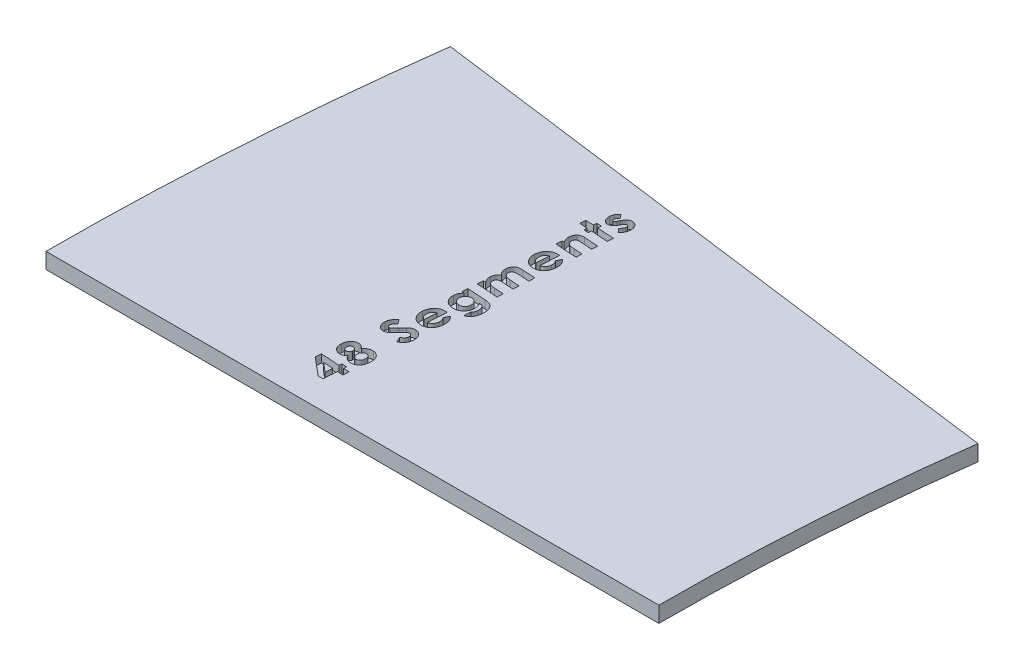
from build123d import *

# Parameters (mm, degrees)
BOSS_EXTRUDE1_DEPTH = 3.175
CUT_EXTRUDE1_DEPTH  = 1.5875


with BuildPart() as part:
    # Sketch1 → Boss-Extrude1 (new body)
    with BuildSketch(Plane(origin=(0, 0, 0), x_dir=(1, 0, 0), z_dir=(0, 1, 0))):
        with BuildLine():
            Line((0, 0), (123.058369544, 0))
            ThreePointArc((123.058369544, 0), (124.044833205, 30.133347612), (127, 60.137659603))
            Line((127, 60.137659603), (4.994411867, 76.2))
            ThreePointArc((4.994411867, 76.2), (1.249941077, 38.181750058), (0, 0))
        make_face()
    extrude(amount=BOSS_EXTRUDE1_DEPTH)

    # Sketch2 → Cut-Extrude1 (cut)
    with BuildSketch(Plane(origin=(0, 3.175, 0), x_dir=(1, 0, 0), z_dir=(0, 1, 0))):
        Polygon((45.403458617, 8.644669615), (45.48041675, 9.838686709), (49.208222072, 9.597318019), (49.244369074, 10.155847499), (50.26348132, 10.090549689), (50.227334318, 9.532020209), (51.415521251, 9.455062076), (51.33972915, 8.286697693), (50.151542217, 8.363655826), (49.975471337, 5.626977975), (48.956359091, 5.692275785), align=None)
        Polygon((49.132429971, 8.428953636), (47.192152193, 8.554885126), (49.040313418, 6.995899916), align=None, mode=Mode.SUBTRACT)
        with BuildLine():
            add(Edge.make_bspline(
                [(48.612358568, 14.746963545), (48.660083235, 14.812453623), (48.753838056, 14.941108488), (48.920903549, 15.108495711), (49.101964982, 15.252658592), (49.300091936, 15.367739108), (49.508431925, 15.456636423), (49.724722624, 15.51677397), (49.947777332, 15.547253835), (50.097811738, 15.543121199), (50.173675843, 15.541031553)],
                knots=[0, 0, 0, 0, 1.058813148, 2.080032062, 3.083098671, 4.079089546, 5.067980208, 6.03892649, 7.008393533, 8, 8, 8, 8], degree=3))
            add(Edge.make_bspline(
                [(50.173675843, 15.541031553), (50.214925689, 15.537212245), (50.29696517, 15.52961624), (50.41839336, 15.510221247), (50.536348025, 15.480685247), (50.651278134, 15.443210922), (50.763403215, 15.397453743), (50.873406157, 15.34421739), (50.979125785, 15.280692541), (51.081849436, 15.210561694), (51.180572226, 15.134919755), (51.27129048, 15.050985709), (51.357274701, 14.964295923), (51.434080169, 14.869780203), (51.505509671, 14.771447769), (51.568399336, 14.666396748), (51.625950063, 14.557455776), (51.674753157, 14.441662665), (51.718505222, 14.320575774), (51.753258491, 14.19136559), (51.780479312, 14.054915264), (51.803800471, 13.911567972), (51.815180276, 13.760270801), (51.822534435, 13.602018332), (51.8228751, 13.435832581), (51.816422809, 13.32282869), (51.813117282, 13.264936468)],
                knots=[0, 0, 0, 0, 0.944636889, 1.878734734, 2.801023885, 3.714840102, 4.633330383, 5.560971107, 6.498930264, 7.44302635, 8.396933534, 9.331872151, 10.259597571, 11.178900164, 12.106286752, 13.02904434, 13.968677379, 14.913771629, 15.89223789, 16.902897162, 17.961587566, 19.064799109, 20.212413555, 21.419099445, 22.677797128, 24, 24, 24, 24], degree=3))
            add(Edge.make_bspline(
                [(51.813117282, 13.264936468), (51.808544104, 13.203481312), (51.799612881, 13.083461981), (51.778540217, 12.90879982), (51.75200781, 12.744179209), (51.719333243, 12.589683891), (51.681195629, 12.445165626), (51.637062859, 12.31071709), (51.586778243, 12.186450666), (51.513134693, 12.035348105), (51.403501941, 11.863722799), (51.246787076, 11.68041689), (51.064293011, 11.522095268), (50.893577005, 11.41129387), (50.747130894, 11.337713495), (50.633753586, 11.289082707), (50.516841757, 11.251200989), (50.397821738, 11.220306768), (50.275680337, 11.199569504), (50.1506561, 11.186916828), (50.022453905, 11.181561808), (49.936184735, 11.18599591), (49.892662054, 11.188232909)],
                knots=[0, 0, 0, 0, 1.154644814, 2.254972708, 3.295486272, 4.278268662, 5.212828494, 6.094946116, 6.928076756, 7.722854426, 9.242249405, 10.729784299, 12.226845655, 13.754110493, 14.529325251, 15.29631934, 16.063278847, 16.829927053, 17.598648219, 18.382065095, 19.183754005, 20, 20, 20, 20], degree=3))
            add(Edge.make_bspline(
                [(49.892662054, 11.188232909), (49.818519314, 11.195685712), (49.672075092, 11.210406236), (49.459711314, 11.26486313), (49.25904995, 11.346297448), (49.070495975, 11.454246251), (48.893883999, 11.588853219), (48.730420284, 11.749879531), (48.578820771, 11.936865322), (48.49088027, 12.075403667), (48.445615947, 12.146711475)],
                knots=[0, 0, 0, 0, 0.986297518, 1.948101384, 2.89298967, 3.847985494, 4.818286911, 5.827091846, 6.881570894, 8, 8, 8, 8], degree=3))
            add(Edge.make_bspline(
                [(48.445615947, 12.146711475), (48.398848976, 12.105123701), (48.307159147, 12.023588041), (48.161318143, 11.916888236), (48.01106566, 11.829581018), (47.859214785, 11.756896262), (47.703199596, 11.704685526), (47.544675123, 11.668971172), (47.382922443, 11.652193594), (47.274552675, 11.655378199), (47.22011598, 11.656977901)],
                knots=[0, 0, 0, 0, 1.105376171, 2.167165192, 3.185955788, 4.172098192, 5.136309341, 6.086007278, 7.038556236, 8, 8, 8, 8], degree=3))
            add(Edge.make_bspline(
                [(47.22011598, 11.656977901), (47.146257343, 11.664443926), (47.000770443, 11.679150518), (46.790728766, 11.740155609), (46.591885052, 11.826118205), (46.407597107, 11.942282016), (46.240175326, 12.083763149), (46.093621018, 12.249069409), (45.970107292, 12.437539554), (45.868732071, 12.64614732), (45.793093249, 12.874400034), (45.745093398, 13.118776704), (45.720291564, 13.377612779), (45.727434075, 13.554470504), (45.73109271, 13.645063004)],
                knots=[0, 0, 0, 0, 0.959435113, 1.889897319, 2.818356756, 3.756692832, 4.699404716, 5.647688167, 6.606595189, 7.608184587, 8.642613508, 9.710508687, 10.827245234, 12, 12, 12, 12], degree=3))
            add(Edge.make_bspline(
                [(45.73109271, 13.645063004), (45.739132865, 13.733980603), (45.754788824, 13.907122814), (45.812227801, 14.156152727), (45.892172609, 14.387351474), (45.997115895, 14.599739846), (46.126342398, 14.790226507), (46.274210202, 14.960468436), (46.446263761, 15.103477511), (46.634489974, 15.223507008), (46.836036438, 15.316702302), (47.045748097, 15.378801759), (47.260627469, 15.412330587), (47.405024617, 15.40874512), (47.477809123, 15.406937837)],
                knots=[0, 0, 0, 0, 1.158948234, 2.256728262, 3.310914617, 4.331802634, 5.324930302, 6.294615419, 7.251644789, 8.221172071, 9.188368295, 10.126338612, 11.055566406, 12, 12, 12, 12], degree=3))
            add(Edge.make_bspline(
                [(47.477809123, 15.406937837), (47.528880635, 15.402220583), (47.62956794, 15.392920534), (47.77645311, 15.35982919), (47.915900955, 15.310381894), (48.051471964, 15.244886098), (48.1857788, 15.156665833), (48.324684661, 15.045017453), (48.469067651, 14.90666803), (48.562933476, 14.802050141), (48.612358568, 14.746963545)],
                knots=[0, 0, 0, 0, 0.909223446, 1.792530799, 2.662713627, 3.529309977, 4.456964102, 5.506950576, 6.68728371, 8, 8, 8, 8], degree=3))
        make_face()
        with BuildLine():
            add(Edge.make_bspline(
                [(46.792182119, 13.53778803), (46.791126306, 13.490625317), (46.789083232, 13.399362066), (46.816341137, 13.267447245), (46.863460381, 13.14585695), (46.937324562, 13.040029297), (47.026774651, 12.949621279), (47.134495058, 12.883037393), (47.254766879, 12.836739632), (47.341349192, 12.82766025), (47.385692569, 12.823010219)],
                knots=[0, 0, 0, 0, 1.085231635, 2.100001469, 3.085829323, 4.073287319, 5.056174103, 5.999140924, 6.975254336, 8, 8, 8, 8], degree=3))
            add(Edge.make_bspline(
                [(47.385692569, 12.823010219), (47.430921453, 12.822250627), (47.518979371, 12.820771748), (47.647514999, 12.851134433), (47.764739634, 12.908941767), (47.870816583, 12.98934007), (47.96010948, 13.090035327), (48.027481157, 13.206764068), (48.073632869, 13.336052736), (48.083667526, 13.427802592), (48.088810057, 13.474822285)],
                knots=[0, 0, 0, 0, 1.012915849, 1.972086262, 2.93248722, 3.92936585, 4.943522166, 5.93315123, 6.940787512, 8, 8, 8, 8], degree=3))
            add(Edge.make_bspline(
                [(48.088810057, 13.474822285), (48.089955132, 13.523539503), (48.092165422, 13.617576264), (48.063896902, 13.753295697), (48.013831077, 13.877235891), (47.938248679, 13.985502176), (47.844947681, 14.077285699), (47.734226399, 14.148025459), (47.606448456, 14.193132873), (47.515476406, 14.203105053), (47.468480864, 14.208256613)],
                knots=[0, 0, 0, 0, 1.082971396, 2.090413337, 3.065299682, 4.043260173, 5.011155227, 5.965228633, 6.948850968, 8, 8, 8, 8], degree=3))
            add(Edge.make_bspline(
                [(47.468480864, 14.208256613), (47.423599796, 14.209108914), (47.336609181, 14.210760884), (47.21113756, 14.179594061), (47.096014618, 14.12603118), (46.997666556, 14.043249393), (46.912134614, 13.943577144), (46.850783753, 13.822511409), (46.807322003, 13.686244636), (46.797370232, 13.588660916), (46.792182119, 13.53778803)],
                knots=[0, 0, 0, 0, 1.003752875, 1.94552146, 2.874347794, 3.829600713, 4.808237546, 5.803459357, 6.854887263, 8, 8, 8, 8], degree=3))
        make_face(mode=Mode.SUBTRACT)
        with BuildLine():
            add(Edge.make_bspline(
                [(49.117250562, 13.434011154), (49.115490541, 13.398647877), (49.112046999, 13.329458414), (49.117031259, 13.227257161), (49.129597575, 13.128907995), (49.150977543, 13.034276291), (49.178729605, 12.942786983), (49.214739731, 12.855144706), (49.259780679, 12.772129335), (49.310286326, 12.693333132), (49.367292377, 12.621041585), (49.428920292, 12.557366906), (49.49334468, 12.501136498), (49.562661665, 12.456272758), (49.634022877, 12.418017942), (49.709659376, 12.389763334), (49.78891109, 12.371219323), (49.843215953, 12.365368065), (49.87050744, 12.362427453)],
                knots=[0, 0, 0, 0, 1.168923599, 2.287039063, 3.37466695, 4.439939738, 5.487661528, 6.529546381, 7.563411425, 8.603237685, 9.617791486, 10.598391904, 11.527199418, 12.435188665, 13.319544345, 14.197070922, 15.093918773, 16, 16, 16, 16], degree=3))
            add(Edge.make_bspline(
                [(49.87050744, 12.362427453), (49.8992874, 12.36132414), (49.955811911, 12.359157205), (50.039409831, 12.368216346), (50.120526, 12.384033079), (50.198561953, 12.410117123), (50.273978503, 12.443836231), (50.345716521, 12.487743219), (50.414333488, 12.540676432), (50.480895647, 12.600930216), (50.54178994, 12.668934926), (50.596526943, 12.743309482), (50.642474892, 12.824444287), (50.684387833, 12.910201372), (50.714794122, 13.003602412), (50.74096821, 13.101924491), (50.759799689, 13.206427946), (50.765470741, 13.278469816), (50.768352325, 13.315075858)],
                knots=[0, 0, 0, 0, 0.944012823, 1.854063158, 2.752145138, 3.651675346, 4.54794375, 5.457994086, 6.404502821, 7.38868266, 8.400336293, 9.395367758, 10.412715021, 11.456897332, 12.521831869, 13.629455457, 14.795474756, 16, 16, 16, 16], degree=3))
            add(Edge.make_bspline(
                [(50.768352325, 13.315075858), (50.769992071, 13.351990521), (50.773202591, 13.424267128), (50.769912248, 13.530719369), (50.758184493, 13.632054917), (50.739591448, 13.727981914), (50.714385886, 13.818480606), (50.679863658, 13.902862867), (50.639210739, 13.982915602), (50.590343967, 14.056908615), (50.536111827, 14.124142526), (50.476796233, 14.183700351), (50.412657241, 14.234897335), (50.34378825, 14.278784229), (50.269451515, 14.311829661), (50.191911071, 14.339960193), (50.108560905, 14.356713331), (50.051297613, 14.36264543), (50.022091641, 14.365670976)],
                knots=[0, 0, 0, 0, 1.225686815, 2.399818307, 3.529117038, 4.606492754, 5.639183039, 6.640145975, 7.626380683, 8.613542342, 9.576226871, 10.48807912, 11.396368183, 12.294438496, 13.188797759, 14.090102707, 15.025895937, 16, 16, 16, 16], degree=3))
            add(Edge.make_bspline(
                [(50.022091641, 14.365670976), (49.992925489, 14.366753833), (49.935243268, 14.368895411), (49.850069363, 14.360002201), (49.767457911, 14.343988448), (49.687957767, 14.318218938), (49.611617312, 14.283009269), (49.538751751, 14.237979594), (49.468970892, 14.184293736), (49.402777648, 14.122464987), (49.341372565, 14.054587927), (49.287149457, 13.980276134), (49.240986644, 13.901042743), (49.200661197, 13.817414651), (49.167972937, 13.72885302), (49.143729662, 13.634630569), (49.12611861, 13.535980915), (49.120230673, 13.468278132), (49.117250562, 13.434011154)],
                knots=[0, 0, 0, 0, 0.965997967, 1.910464878, 2.829836423, 3.750289794, 4.672273579, 5.608804393, 6.582498314, 7.58489814, 8.606311822, 9.610942972, 10.626983754, 11.640818325, 12.683923904, 13.749136132, 14.860751353, 16, 16, 16, 16], degree=3))
        make_face(mode=Mode.SUBTRACT)
        with BuildLine():
            Line((47.31786749, 23.569500264), (47.981339879, 22.641338539))
            add(Edge.make_bspline(
                [(47.981339879, 22.641338539), (47.931383169, 22.606364631), (47.835539776, 22.539266179), (47.70639689, 22.429675712), (47.594625686, 22.319346271), (47.50212321, 22.205915871), (47.427149176, 22.091540452), (47.373187914, 21.974282928), (47.334973998, 21.855653687), (47.325879119, 21.77445969), (47.321365587, 21.734165395)],
                knots=[0, 0, 0, 0, 1.259962512, 2.417274506, 3.496694533, 4.501793993, 5.437824047, 6.314896232, 7.163730449, 8, 8, 8, 8], degree=3))
            add(Edge.make_bspline(
                [(47.321365587, 21.734165395), (47.320211985, 21.696810578), (47.317989438, 21.624842226), (47.333444486, 21.520818999), (47.363712603, 21.42596724), (47.408707656, 21.342711011), (47.464020548, 21.274051882), (47.5259145, 21.22200974), (47.593413595, 21.187147372), (47.641666905, 21.180207424), (47.665345121, 21.176801947)],
                knots=[0, 0, 0, 0, 1.240335475, 2.389648993, 3.47647956, 4.534434871, 5.517131834, 6.388931619, 7.209438151, 8, 8, 8, 8], degree=3))
            add(Edge.make_bspline(
                [(47.665345121, 21.176801947), (47.689528087, 21.176659324), (47.738025637, 21.176373302), (47.810158094, 21.19280456), (47.881590461, 21.220630367), (47.925059894, 21.249390899), (47.947524942, 21.264254371)],
                knots=[0, 0, 0, 0, 0.961218949, 1.9276694, 2.929017405, 4, 4, 4, 4], degree=3))
            add(Edge.make_bspline(
                [(47.947524942, 21.264254371), (47.965161134, 21.278070251), (48.006204463, 21.31022287), (48.072409902, 21.370170963), (48.150819825, 21.44886094), (48.244525398, 21.543293502), (48.351596778, 21.655089344), (48.471542292, 21.785039652), (48.605703969, 21.931555558), (48.698590459, 22.036040859), (48.747423113, 22.090971284)],
                knots=[0, 0, 0, 0, 0.466860746, 1.086488491, 1.859851877, 2.782151811, 3.859346126, 5.08609297, 6.468089265, 8, 8, 8, 8], degree=3))
            add(Edge.make_bspline(
                [(48.747423113, 22.090971284), (48.792976655, 22.142207089), (48.87951575, 22.239540908), (49.001056568, 22.378663621), (49.11144539, 22.500013091), (49.207683393, 22.605878147), (49.291004283, 22.69591274), (49.359936574, 22.770769224), (49.417564576, 22.827850128), (49.451297599, 22.860574288), (49.465699021, 22.874545002)],
                knots=[0, 0, 0, 0, 1.547564171, 2.939942712, 4.169874708, 5.250488515, 6.169415565, 6.939095653, 7.547074963, 8, 8, 8, 8], degree=3))
            add(Edge.make_bspline(
                [(49.465699021, 22.874545002), (49.524357116, 22.927974281), (49.636774275, 23.030370509), (49.810539432, 23.161896192), (49.977723524, 23.269213384), (50.142773084, 23.348783191), (50.308213792, 23.406518187), (50.477914458, 23.44176435), (50.653108547, 23.460754716), (50.77123259, 23.456314371), (50.831122865, 23.454063065)],
                knots=[0, 0, 0, 0, 1.242832467, 2.381865548, 3.411028091, 4.350899025, 5.246607285, 6.149760917, 7.061907069, 8, 8, 8, 8], degree=3))
            add(Edge.make_bspline(
                [(50.831122865, 23.454063065), (50.889227245, 23.44875077), (51.003266649, 23.438324516), (51.168679003, 23.400762177), (51.326406726, 23.350182272), (51.474405532, 23.280928664), (51.613655693, 23.196101841), (51.743644957, 23.094955116), (51.865492068, 22.977952007), (51.976141522, 22.845100138), (52.077302822, 22.701452115), (52.160419056, 22.545192732), (52.231217423, 22.381306011), (52.286378738, 22.20796581), (52.323945609, 22.024952213), (52.349038746, 21.833246187), (52.356667324, 21.631921706), (52.351018759, 21.495111495), (52.348130912, 21.425166831)],
                knots=[0, 0, 0, 0, 0.985764863, 1.934725727, 2.861807049, 3.782293506, 4.690921729, 5.613916041, 6.562284815, 7.541938189, 8.533864006, 9.527987119, 10.529191171, 11.549905542, 12.598020906, 13.684831924, 14.81636282, 16, 16, 16, 16], degree=3))
            add(Edge.make_bspline(
                [(52.348130912, 21.425166831), (52.343779082, 21.370287272), (52.335197934, 21.262073117), (52.310446031, 21.103546148), (52.276562866, 20.950852606), (52.233362323, 20.804518677), (52.182489518, 20.66330934), (52.119926739, 20.529466485), (52.050194965, 20.400460006), (51.97047784, 20.277801087), (51.881396405, 20.159996259), (51.780927956, 20.048728442), (51.671067656, 19.94191003), (51.549668106, 19.841351853), (51.418545384, 19.745059776), (51.27670761, 19.653433079), (51.123886041, 19.568807049), (51.017159917, 19.51704349), (50.962884517, 19.490719214)],
                knots=[0, 0, 0, 0, 1.050146701, 2.070729804, 3.058558941, 4.032481406, 4.980388222, 5.919492294, 6.848763778, 7.776524707, 8.708042668, 9.663923483, 10.634224774, 11.629376606, 12.669206861, 13.73688427, 14.849096104, 16, 16, 16, 16], degree=3))
            Line((50.962884517, 19.490719214), (50.468486814, 20.528487978))
            add(Edge.make_bspline(
                [(50.468486814, 20.528487978), (50.531654807, 20.562049824), (50.652535394, 20.626275004), (50.817473032, 20.735204708), (50.95839394, 20.850719967), (51.076060659, 20.971939781), (51.170537588, 21.099371696), (51.239443418, 21.233335809), (51.287884469, 21.373145246), (51.298191394, 21.469882684), (51.303365954, 21.518449416)],
                knots=[0, 0, 0, 0, 1.264744856, 2.420262152, 3.489788695, 4.481701623, 5.401647069, 6.284145582, 7.138560588, 8, 8, 8, 8], degree=3))
            add(Edge.make_bspline(
                [(51.303365954, 21.518449416), (51.304558201, 21.567887979), (51.306872437, 21.663851799), (51.284113531, 21.802989691), (51.240991755, 21.931730635), (51.175721697, 22.045228556), (51.098125917, 22.14265399), (51.008179592, 22.215248299), (50.909367427, 22.264695969), (50.838649904, 22.274020195), (50.80313809, 22.278702488)],
                knots=[0, 0, 0, 0, 1.179276943, 2.289061677, 3.349098182, 4.4052234, 5.401529699, 6.306411478, 7.149540335, 8, 8, 8, 8], degree=3))
            add(Edge.make_bspline(
                [(50.80313809, 22.278702488), (50.76996628, 22.278900624), (50.702358223, 22.27930445), (50.600112523, 22.25356888), (50.49708846, 22.210049805), (50.411551927, 22.156940176), (50.339769458, 22.101427103), (50.277402538, 22.047810182), (50.207180411, 21.983490028), (50.130347285, 21.907482653), (50.046488406, 21.819531402), (49.954369825, 21.720753595), (49.855691314, 21.609952708), (49.787838099, 21.53211791), (49.752542971, 21.491630673)],
                knots=[0, 0, 0, 0, 0.878417966, 1.790319345, 2.776241537, 3.842568915, 4.454011902, 5.186637811, 6.027267838, 6.983979148, 8.057732953, 9.256214254, 10.572768142, 12, 12, 12, 12], degree=3))
            add(Edge.make_bspline(
                [(49.752542971, 21.491630673), (49.685352759, 21.413504912), (49.556444071, 21.263615679), (49.36425605, 21.054450969), (49.18766918, 20.864542479), (49.022275668, 20.697418288), (48.868105853, 20.552977836), (48.728135217, 20.428566993), (48.599256533, 20.327875069), (48.481874758, 20.245780561), (48.369397316, 20.182055393), (48.260922111, 20.127975981), (48.153100441, 20.08325016), (48.045549952, 20.047915962), (47.938148956, 20.022723802), (47.831949669, 20.004375232), (47.72603968, 19.997224765), (47.656014158, 20.000036759), (47.621035893, 20.00144137)],
                knots=[0, 0, 0, 0, 1.836570026, 3.523576208, 5.06257668, 6.458740922, 7.713443808, 8.827894704, 9.795229329, 10.627303203, 11.378337667, 12.097142506, 12.786742063, 13.457143101, 14.112483532, 14.751433223, 15.37633167, 16, 16, 16, 16], degree=3))
            add(Edge.make_bspline(
                [(47.621035893, 20.00144137), (47.571881903, 20.006112347), (47.474616852, 20.015355193), (47.332978441, 20.049385806), (47.196617904, 20.095195516), (47.067698643, 20.159012585), (46.945463124, 20.238355403), (46.828602967, 20.331618693), (46.718588551, 20.440856687), (46.617320652, 20.564150043), (46.523813317, 20.69647796), (46.446329194, 20.838795698), (46.379612191, 20.985936064), (46.330408785, 21.140826396), (46.292466848, 21.300946899), (46.269485297, 21.467612852), (46.259667407, 21.640829419), (46.264704963, 21.758267165), (46.267272371, 21.818119722)],
                knots=[0, 0, 0, 0, 0.940109522, 1.860272196, 2.769362089, 3.677243568, 4.593820015, 5.54261843, 6.522299789, 7.543004526, 8.580907746, 9.605637889, 10.62720271, 11.655755738, 12.69809198, 13.760535432, 14.858649072, 16, 16, 16, 16], degree=3))
            add(Edge.make_bspline(
                [(46.267272371, 21.818119722), (46.274817966, 21.895351776), (46.289824173, 22.048946056), (46.343973231, 22.274097086), (46.420787819, 22.492074759), (46.506417624, 22.66696984), (46.587675242, 22.805329403), (46.662401834, 22.909522757), (46.744237147, 23.017620919), (46.840024058, 23.124120355), (46.943824948, 23.234146981), (47.0576829, 23.346387851), (47.18435577, 23.457599138), (47.272633181, 23.531587711), (47.31786749, 23.569500264)],
                knots=[0, 0, 0, 0, 1.323588687, 2.632270434, 3.942011782, 5.26276926, 5.950186656, 6.679234955, 7.450436607, 8.263881052, 9.122931744, 10.033328008, 10.992255797, 12, 12, 12, 12], degree=3))
        make_face()
        with BuildLine():
            Line((50.902312635, 29.667928965), (50.660943945, 25.92846332))
            add(Edge.make_bspline(
                [(50.660943945, 25.92846332), (50.698392047, 25.933564462), (50.77238895, 25.943644244), (50.879870172, 25.971279678), (50.982574698, 26.005944337), (51.080140561, 26.049032082), (51.171742276, 26.102150501), (51.257967622, 26.163944182), (51.339074006, 26.234676775), (51.414866327, 26.313553721), (51.482920193, 26.401324411), (51.545860167, 26.494340988), (51.597399568, 26.59566263), (51.644055607, 26.701782088), (51.679313001, 26.815911152), (51.708800469, 26.936113095), (51.729833579, 27.063214817), (51.737027908, 27.150397716), (51.740689872, 27.194774418)],
                knots=[0, 0, 0, 0, 0.994835371, 1.965780117, 2.917698247, 3.848119578, 4.770108853, 5.702049976, 6.638255784, 7.601395555, 8.578421378, 9.560957341, 10.554738414, 11.568415358, 12.611048672, 13.696247782, 14.82737411, 16, 16, 16, 16], degree=3))
            add(Edge.make_bspline(
                [(51.740689872, 27.194774418), (51.74274016, 27.248406898), (51.746784382, 27.354197696), (51.737497566, 27.510796652), (51.713603536, 27.662445957), (51.678086269, 27.809517915), (51.627407237, 27.95164007), (51.562953795, 28.088047803), (51.485654955, 28.220293268), (51.424338717, 28.30266648), (51.393212241, 28.344482284)],
                knots=[0, 0, 0, 0, 1.047388229, 2.065987588, 3.056531067, 4.041127734, 5.015525619, 5.996519287, 6.982956295, 8, 8, 8, 8], degree=3))
            Line((51.393212241, 28.344482284), (51.881779782, 29.297130688))
            add(Edge.make_bspline(
                [(51.881779782, 29.297130688), (51.91869169, 29.263715251), (51.992085495, 29.197273655), (52.094426663, 29.091594324), (52.187674813, 28.981023497), (52.274993922, 28.868510495), (52.351163668, 28.7497575), (52.422341546, 28.628900428), (52.48206814, 28.502185859), (52.53658665, 28.372633288), (52.581777123, 28.237609948), (52.620602271, 28.097624326), (52.650673843, 27.951904888), (52.672702978, 27.800408167), (52.687599892, 27.643569519), (52.695924372, 27.48134262), (52.696074203, 27.313588322), (52.689631434, 27.20019557), (52.686342082, 27.142302964)],
                knots=[0, 0, 0, 0, 0.998802116, 1.985968494, 2.948526296, 3.899932011, 4.840796933, 5.77709413, 6.711831264, 7.648810172, 8.59576323, 9.56627996, 10.561911074, 11.578724665, 12.636344111, 13.721659964, 14.836794776, 16, 16, 16, 16], degree=3))
            add(Edge.make_bspline(
                [(52.686342082, 27.142302964), (52.678965936, 27.053489578), (52.664518939, 26.879538737), (52.616789387, 26.626900405), (52.551924686, 26.38799047), (52.467717959, 26.162510252), (52.364096765, 25.950999685), (52.240314402, 25.753856122), (52.099453458, 25.569487885), (51.938278558, 25.403222013), (51.765851042, 25.252581359), (51.58194254, 25.123988623), (51.390141606, 25.016518099), (51.188424102, 24.934043671), (50.97916654, 24.869658307), (50.759934341, 24.83105541), (50.532545011, 24.812485559), (50.378778684, 24.818726977), (50.300639958, 24.82189865)],
                knots=[0, 0, 0, 0, 1.146840864, 2.246214718, 3.304922167, 4.331146756, 5.340564401, 6.332044593, 7.324042507, 8.322207038, 9.308533163, 10.267917242, 11.206557428, 12.133179881, 13.068880295, 14.020084305, 14.993875368, 16, 16, 16, 16], degree=3))
            add(Edge.make_bspline(
                [(50.300639958, 24.82189865), (50.220757174, 24.829336226), (50.063789788, 24.843950851), (49.835235957, 24.891275579), (49.618532952, 24.958537109), (49.413830278, 25.048103973), (49.220992907, 25.158237314), (49.038977469, 25.287940998), (48.870300906, 25.440237372), (48.714182864, 25.610457781), (48.573513121, 25.795401539), (48.454418564, 25.992944579), (48.353738576, 26.198763771), (48.277753003, 26.415583746), (48.219678197, 26.640930785), (48.183780193, 26.87602365), (48.169761742, 27.120833085), (48.176299275, 27.286508898), (48.179627171, 27.370845298)],
                knots=[0, 0, 0, 0, 1.038080059, 2.039797629, 3.015440869, 3.970929085, 4.926536557, 5.885912811, 6.858800873, 7.863156722, 8.872630486, 9.861665724, 10.845219295, 11.833652654, 12.830809453, 13.854247172, 14.907715822, 16, 16, 16, 16], degree=3))
            add(Edge.make_bspline(
                [(48.179627171, 27.370845298), (48.187498774, 27.460032712), (48.202880228, 27.634308779), (48.25011252, 27.887960849), (48.316531209, 28.127478172), (48.401232486, 28.353632765), (48.506782098, 28.565068066), (48.632714164, 28.761695027), (48.775949421, 28.946027929), (48.939659196, 29.112873555), (49.116698366, 29.264122009), (49.309580268, 29.390814418), (49.511900252, 29.498564696), (49.727059341, 29.581227876), (49.953343796, 29.64212404), (50.191277284, 29.680083932), (50.440789146, 29.697099741), (50.610413991, 29.690141228), (50.697090947, 29.686585482)],
                knots=[0, 0, 0, 0, 1.116171507, 2.181047453, 3.212496527, 4.21276363, 5.18831663, 6.153857981, 7.120676207, 8.094252009, 9.064370131, 10.01894602, 10.966517271, 11.918048095, 12.886990705, 13.883963422, 14.918722022, 16, 16, 16, 16], degree=3))
            Line((50.697090947, 29.686585482), (50.902312635, 29.667928965))
        make_face()
        with BuildLine():
            add(Edge.make_bspline(
                [(49.979981071, 28.554368101), (49.920807671, 28.536297754), (49.802732665, 28.500240059), (49.64045465, 28.407344762), (49.49202244, 28.288002019), (49.363067546, 28.139540776), (49.253485719, 27.970746321), (49.171338108, 27.782775026), (49.113857556, 27.580291427), (49.099795983, 27.438457174), (49.092630477, 27.366181169)],
                knots=[0, 0, 0, 0, 0.934306292, 1.864321171, 2.810085895, 3.806617566, 4.828527451, 5.845545187, 6.902131309, 8, 8, 8, 8], degree=3))
            add(Edge.make_bspline(
                [(49.092630477, 27.366181169), (49.09089294, 27.326155912), (49.087467842, 27.247256593), (49.092260728, 27.130291027), (49.105640711, 27.016689448), (49.124235769, 26.905948138), (49.154719828, 26.79925384), (49.190267704, 26.694699778), (49.235598021, 26.593820889), (49.27171815, 26.529493548), (49.289689938, 26.497487092)],
                knots=[0, 0, 0, 0, 1.062818384, 2.095068298, 3.101963213, 4.097381956, 5.07075439, 6.042814411, 7.026190488, 8, 8, 8, 8], degree=3))
            add(Edge.make_bspline(
                [(49.289689938, 26.497487092), (49.317181098, 26.456803614), (49.375524221, 26.37046309), (49.496509977, 26.254613969), (49.644387411, 26.139056641), (49.757981041, 26.070654782), (49.817902579, 26.034572261)],
                knots=[0, 0, 0, 0, 0.828720824, 1.758753057, 2.81772453, 4, 4, 4, 4], degree=3))
            Line((49.817902579, 26.034572261), (49.979981071, 28.554368101))
        make_face(mode=Mode.SUBTRACT)
        with BuildLine():
            Line((48.771568378, 34.721687852), (48.847360478, 35.881890009))
            Line((48.847360478, 35.881890009), (52.51453212, 35.644019416))
            add(Edge.make_bspline(
                [(52.51453212, 35.644019416), (52.602087328, 35.636868115), (52.771563323, 35.62302572), (53.015769491, 35.58645676), (53.240530515, 35.533734962), (53.446540627, 35.468706635), (53.634920037, 35.391334801), (53.80298526, 35.297520399), (53.954014891, 35.191877639), (54.039570567, 35.108078078), (54.081679556, 35.066833418)],
                knots=[0, 0, 0, 0, 1.23386892, 2.388334938, 3.465088934, 4.473544334, 5.420668639, 6.320116555, 7.173191121, 8, 8, 8, 8], degree=3))
            add(Edge.make_bspline(
                [(54.081679556, 35.066833418), (54.133885584, 35.008285271), (54.238543849, 34.890912859), (54.36624236, 34.689528888), (54.473000478, 34.471867206), (54.556294527, 34.234727587), (54.614995327, 33.978879428), (54.650159261, 33.704397685), (54.664928589, 33.411869963), (54.655541018, 33.211272758), (54.650703327, 33.107899123)],
                knots=[0, 0, 0, 0, 0.894926534, 1.794073614, 2.713572071, 3.660174313, 4.658680894, 5.706853178, 6.818274054, 8, 8, 8, 8], degree=3))
            add(Edge.make_bspline(
                [(54.650703327, 33.107899123), (54.642235285, 32.998883896), (54.625955136, 32.789297765), (54.576298734, 32.490063442), (54.511554472, 32.218346428), (54.425634806, 31.973996562), (54.322048707, 31.754150302), (54.203349539, 31.553668469), (54.064342912, 31.374701972), (53.910425133, 31.213780194), (53.739343782, 31.074203839), (53.55193345, 30.956970447), (53.349872856, 30.859998631), (53.206247368, 30.814926847), (53.133695281, 30.792158939)],
                knots=[0, 0, 0, 0, 1.323068853, 2.543652737, 3.66767639, 4.700400896, 5.67279012, 6.605568507, 7.514657804, 8.409759522, 9.29596319, 10.17971546, 11.080487429, 12, 12, 12, 12], degree=3))
            Line((53.133695281, 30.792158939), (53.216483575, 32.075960522))
            add(Edge.make_bspline(
                [(53.216483575, 32.075960522), (53.247588085, 32.103952835), (53.310140958, 32.16024691), (53.391014765, 32.260407083), (53.46245453, 32.372350774), (53.521747732, 32.498424889), (53.570247566, 32.636948089), (53.610374347, 32.788019317), (53.637793162, 32.95243132), (53.647554626, 33.066611557), (53.652579662, 33.125389608)],
                knots=[0, 0, 0, 0, 0.858486583, 1.726463573, 2.634642424, 3.581081705, 4.581170094, 5.646362337, 6.788387222, 8, 8, 8, 8], degree=3))
            add(Edge.make_bspline(
                [(53.652579662, 33.125389608), (53.655766822, 33.199999474), (53.661829564, 33.341925332), (53.651207002, 33.544837881), (53.620352141, 33.725788125), (53.570973603, 33.884930525), (53.508282073, 34.023303114), (53.433725747, 34.141929052), (53.346241477, 34.238945022), (53.26336069, 34.304947558), (53.188196795, 34.347258472), (53.121860715, 34.374907675), (53.04600037, 34.400641124), (52.959763188, 34.422356468), (52.8638768, 34.440523604), (52.758566266, 34.457144421), (52.643383158, 34.469758356), (52.563140625, 34.475177058), (52.521528314, 34.477987098)],
                knots=[0, 0, 0, 0, 1.73616652, 3.302605099, 4.715916807, 5.993939219, 7.166982346, 8.240207595, 9.238649617, 10.19161721, 10.689445005, 11.240185385, 11.86049324, 12.551111064, 13.306326133, 14.129662517, 15.030077156, 16, 16, 16, 16], degree=3))
            add(Edge.make_bspline(
                [(52.521528314, 34.477987098), (52.562843416, 34.424222809), (52.64373363, 34.318958522), (52.74757166, 34.153191246), (52.827747769, 33.982694886), (52.891042237, 33.809645594), (52.934181162, 33.629603561), (52.960641677, 33.441060428), (52.971514215, 33.242421435), (52.965409516, 33.107112795), (52.96228853, 33.037937184)],
                knots=[0, 0, 0, 0, 1.052449834, 2.060575592, 3.029617018, 3.972603352, 4.916651097, 5.898089827, 6.925412889, 8, 8, 8, 8], degree=3))
            add(Edge.make_bspline(
                [(52.96228853, 33.037937184), (52.955559157, 32.96156481), (52.94232219, 32.811337049), (52.89814624, 32.592442532), (52.837050286, 32.383459582), (52.754020851, 32.185796612), (52.655677739, 31.996831662), (52.535104928, 31.819581942), (52.395876367, 31.653053207), (52.240803187, 31.497371911), (52.071214444, 31.358012963), (51.891304509, 31.237530612), (51.702396721, 31.136600368), (51.502743717, 31.060917138), (51.295976668, 31.001119675), (51.079227237, 30.965664355), (50.853883238, 30.950097677), (50.700968199, 30.955934286), (50.623227699, 30.958901561)],
                knots=[0, 0, 0, 0, 1.05170353, 2.068746279, 3.059633396, 4.035584716, 5.006931398, 5.979142195, 6.97170843, 7.982772074, 8.991072858, 9.979543945, 10.950890627, 11.923847754, 12.905151095, 13.900681141, 14.93272697, 16, 16, 16, 16], degree=3))
            add(Edge.make_bspline(
                [(50.623227699, 30.958901561), (50.540232046, 30.966277428), (50.378222194, 30.980675328), (50.14311479, 31.028205194), (49.921946083, 31.095040613), (49.715218057, 31.184895243), (49.521398797, 31.293250698), (49.34214143, 31.423889001), (49.176219879, 31.574546351), (49.079336136, 31.689240051), (49.030427552, 31.747139408)],
                knots=[0, 0, 0, 0, 1.090293312, 2.128283224, 3.134407262, 4.110041328, 5.073951069, 6.035924274, 7.008500711, 8, 8, 8, 8], degree=3))
            add(Edge.make_bspline(
                [(49.030427552, 31.747139408), (48.988879336, 31.801949904), (48.906871585, 31.910134704), (48.804400418, 32.084548892), (48.718086226, 32.264410083), (48.652762124, 32.451774676), (48.600728912, 32.643930447), (48.571718501, 32.843461639), (48.557935313, 33.049073509), (48.563518419, 33.187960431), (48.56634669, 33.258317293)],
                knots=[0, 0, 0, 0, 1.018991757, 2.011282992, 2.993431462, 3.972260481, 4.949323578, 5.940409194, 6.956659527, 8, 8, 8, 8], degree=3))
            add(Edge.make_bspline(
                [(48.56634669, 33.258317293), (48.571993666, 33.324190518), (48.58316638, 33.454522678), (48.623328671, 33.645004683), (48.676351863, 33.829623976), (48.748290156, 34.008102325), (48.839272059, 34.183538335), (48.953225292, 34.355331616), (49.087773716, 34.526950372), (49.190761364, 34.634701272), (49.243811467, 34.69020498)],
                knots=[0, 0, 0, 0, 0.977655822, 1.934321496, 2.875416415, 3.817565586, 4.777253035, 5.795169511, 6.864266874, 8, 8, 8, 8], degree=3))
            Line((49.243811467, 34.69020498), (48.771568378, 34.721687852))
        make_face()
        with BuildLine():
            add(Edge.make_bspline(
                [(49.586624968, 33.456542787), (49.584581538, 33.411840714), (49.580562506, 33.323920415), (49.589672672, 33.194031102), (49.607349727, 33.068891958), (49.63861836, 32.949833141), (49.677586108, 32.835050636), (49.730710534, 32.72685229), (49.794204737, 32.62357134), (49.867143243, 32.525990448), (49.949102241, 32.436741757), (50.038942025, 32.358477187), (50.132786936, 32.288154679), (50.235596151, 32.233452856), (50.342359039, 32.184888398), (50.456745314, 32.151272454), (50.576804993, 32.125725021), (50.659251828, 32.118254354), (50.701351865, 32.114439588)],
                knots=[0, 0, 0, 0, 1.099286497, 2.162083149, 3.195917688, 4.201772293, 5.18397263, 6.171226687, 7.157833092, 8.16118811, 9.1620373, 10.130192105, 11.08777292, 12.03726183, 12.987135343, 13.966496071, 14.961626729, 16, 16, 16, 16], degree=3))
            add(Edge.make_bspline(
                [(50.701351865, 32.114439588), (50.744880579, 32.112953959), (50.830464781, 32.110032982), (50.957117076, 32.117862642), (51.07859943, 32.139011797), (51.194707732, 32.171696023), (51.305617211, 32.216213594), (51.410239159, 32.273875687), (51.510720188, 32.341974013), (51.604187465, 32.422092782), (51.68992324, 32.51129384), (51.766304505, 32.60781804), (51.833174518, 32.710053013), (51.887973666, 32.819970578), (51.933912811, 32.935662137), (51.96862773, 33.058754724), (51.993484792, 33.188301814), (52.001105212, 33.277261886), (52.004975997, 33.32244907)],
                knots=[0, 0, 0, 0, 1.049641304, 2.063757524, 3.052757436, 4.016806391, 4.9668646, 5.927080707, 6.891311799, 7.888357884, 8.889051898, 9.869536743, 10.851989716, 11.828391526, 12.825437611, 13.848690198, 14.907244222, 16, 16, 16, 16], degree=3))
            add(Edge.make_bspline(
                [(52.004975997, 33.32244907), (52.007053892, 33.366764651), (52.011121951, 33.453524739), (52.001656174, 33.581394183), (51.985303577, 33.704167096), (51.955834933, 33.821840281), (51.91458998, 33.933516681), (51.864487828, 34.04104511), (51.802264185, 34.142358439), (51.730354559, 34.237974193), (51.648565267, 34.324946745), (51.560372076, 34.403803938), (51.46318027, 34.470619614), (51.359929605, 34.527866197), (51.24876059, 34.57374622), (51.130327372, 34.608555982), (51.004588592, 34.633217643), (50.917945798, 34.640851259), (50.873924648, 34.644729719)],
                knots=[0, 0, 0, 0, 1.088637655, 2.131311298, 3.143833221, 4.127827658, 5.10326465, 6.064064433, 7.036554126, 8.017905593, 8.997258521, 9.964439286, 10.917764508, 11.88762686, 12.859132132, 13.86492656, 14.915219801, 16, 16, 16, 16], degree=3))
            add(Edge.make_bspline(
                [(50.873924648, 34.644729719), (50.83038565, 34.646872024), (50.744762688, 34.651085039), (50.618694068, 34.640600467), (50.497904168, 34.621473335), (50.382847451, 34.589941355), (50.273878632, 34.545954509), (50.169008823, 34.492833022), (50.071330648, 34.425414171), (49.979214257, 34.348888938), (49.895241676, 34.262463177), (49.820776973, 34.168184474), (49.756190635, 34.06688934), (49.700741341, 33.95905956), (49.656561712, 33.843222233), (49.623405693, 33.720426521), (49.597827533, 33.591129969), (49.590419675, 33.502132249), (49.586624968, 33.456542787)],
                knots=[0, 0, 0, 0, 1.062269978, 2.089039862, 3.078810452, 4.04258257, 4.991550764, 5.941418433, 6.903883867, 7.879890143, 8.858793337, 9.837558777, 10.805426131, 11.784926035, 12.790330647, 13.823123717, 14.884885837, 16, 16, 16, 16], degree=3))
        make_face(mode=Mode.SUBTRACT)
        with BuildLine():
            Line((48.965376479, 37.622471739), (49.041168579, 38.790836122))
            Line((49.041168579, 38.790836122), (49.533234218, 38.758187217))
            add(Edge.make_bspline(
                [(49.533234218, 38.758187217), (49.488337848, 38.81183691), (49.399907725, 38.917508013), (49.28557707, 39.087471404), (49.193914508, 39.26575811), (49.119085353, 39.450000783), (49.065662668, 39.641748532), (49.03206132, 39.840632247), (49.016218215, 40.04644509), (49.021165958, 40.18578908), (49.023678094, 40.256538746)],
                knots=[0, 0, 0, 0, 1.031658313, 2.032005508, 3.014292284, 3.984335048, 4.961032546, 5.944272861, 6.956237665, 8, 8, 8, 8], degree=3))
            add(Edge.make_bspline(
                [(49.023678094, 40.256538746), (49.03080592, 40.32718362), (49.044784141, 40.465723722), (49.096428754, 40.665817007), (49.169779272, 40.854399212), (49.268408516, 41.02937069), (49.388004248, 41.19055115), (49.532912363, 41.330947027), (49.696914374, 41.45591957), (49.820170986, 41.520317461), (49.883043913, 41.553166684)],
                knots=[0, 0, 0, 0, 1.041543059, 2.042547098, 3.024156365, 4.005549828, 4.983983622, 5.960850829, 6.959834478, 8, 8, 8, 8], degree=3))
            add(Edge.make_bspline(
                [(49.883043913, 41.553166684), (49.825793405, 41.604743316), (49.712956065, 41.706397787), (49.567186353, 41.880012721), (49.445307161, 42.067695653), (49.346645207, 42.268720296), (49.275106535, 42.481494203), (49.226657413, 42.702306881), (49.203948204, 42.930983425), (49.20890111, 43.085306827), (49.211409298, 43.163457316)],
                knots=[0, 0, 0, 0, 1.019502353, 2.00937841, 2.991610522, 3.976858928, 4.966507462, 5.95691866, 6.965368817, 8, 8, 8, 8], degree=3))
            add(Edge.make_bspline(
                [(49.211409298, 43.163457316), (49.21909053, 43.243456503), (49.234087713, 43.399650507), (49.290276995, 43.623556101), (49.369109502, 43.831758396), (49.475512265, 44.019738579), (49.600772064, 44.186256459), (49.741315341, 44.328235207), (49.897255844, 44.44229302), (50.041065353, 44.513584988), (50.16735112, 44.557211223), (50.275835516, 44.58377301), (50.397656771, 44.602461807), (50.53177387, 44.618267032), (50.67896865, 44.625536945), (50.839194332, 44.627766281), (51.012651143, 44.624240695), (51.132658964, 44.617495789), (51.194830271, 44.61400152)],
                knots=[0, 0, 0, 0, 1.361599759, 2.658448465, 3.902432903, 5.127491301, 6.308982219, 7.427869127, 8.503980096, 9.571350542, 10.136399201, 10.768030983, 11.462814057, 12.225850175, 13.057862326, 13.961213864, 14.943785509, 16, 16, 16, 16], degree=3))
            Line((51.194830271, 44.61400152), (53.705297853, 44.451923027))
            Line((53.705297853, 44.451923027), (53.630671784, 43.280060547))
            Line((53.630671784, 43.280060547), (51.458353575, 43.421150458))
            add(Edge.make_bspline(
                [(51.458353575, 43.421150458), (51.400070755, 43.424346685), (51.288224624, 43.430480323), (51.127525682, 43.431743059), (50.981216602, 43.426110115), (50.848968149, 43.414302204), (50.731093572, 43.392788836), (50.626268986, 43.367234249), (50.536326478, 43.332330231), (50.459383302, 43.290860679), (50.394252152, 43.242066715), (50.337547261, 43.186943665), (50.289867486, 43.124337881), (50.248130112, 43.055836533), (50.215007151, 42.980438738), (50.188673119, 42.898481283), (50.171705819, 42.809938155), (50.165878988, 42.748410916), (50.16289167, 42.716866938)],
                knots=[0, 0, 0, 0, 1.656984254, 3.179792524, 4.560214641, 5.81301306, 6.945063533, 7.95940246, 8.87127323, 9.676190726, 10.433164267, 11.174453009, 11.913850391, 12.661354815, 13.446748366, 14.245896858, 15.100700869, 16, 16, 16, 16], degree=3))
            add(Edge.make_bspline(
                [(50.16289167, 42.716866938), (50.161975423, 42.668236981), (50.160170825, 42.572457633), (50.180033671, 42.4310682), (50.221785342, 42.296484411), (50.282277656, 42.169383543), (50.361225836, 42.052494028), (50.458762178, 41.950275199), (50.57024373, 41.860570076), (50.677051782, 41.79861863), (50.773707544, 41.757866476), (50.85717379, 41.7281322), (50.95214424, 41.703270596), (51.057490312, 41.679908381), (51.173946119, 41.660508423), (51.300644558, 41.642828576), (51.438391559, 41.629265996), (51.533741588, 41.6221497), (51.583119033, 41.618464494)],
                knots=[0, 0, 0, 0, 1.141810146, 2.248857258, 3.338126037, 4.44124717, 5.54584218, 6.637864926, 7.749124504, 8.8990895, 9.52516469, 10.212721002, 10.979394562, 11.830444151, 12.747964216, 13.752974077, 14.836367432, 16, 16, 16, 16], degree=3))
            Line((51.583119033, 41.618464494), (53.515234585, 41.493699036))
            Line((53.515234585, 41.493699036), (53.439442484, 40.320670523))
            Line((53.439442484, 40.320670523), (51.36507099, 40.45476424))
            add(Edge.make_bspline(
                [(51.36507099, 40.45476424), (51.318834233, 40.457866169), (51.229915504, 40.463831544), (51.100788897, 40.466347635), (50.981413673, 40.468800967), (50.871801343, 40.464336698), (50.771685736, 40.459719993), (50.68158493, 40.448477826), (50.600245758, 40.436818233), (50.507855419, 40.413394256), (50.404651014, 40.378301547), (50.294769471, 40.322079276), (50.200026429, 40.25300861), (50.121752751, 40.170329034), (50.061363768, 40.075396442), (50.013222603, 39.971511855), (49.983393593, 39.855693994), (49.974883808, 39.774732384), (49.970496337, 39.732990235)],
                knots=[0, 0, 0, 0, 1.241262427, 2.387093803, 3.459660388, 4.43895979, 5.325575809, 6.143161178, 6.870715556, 7.524817004, 8.69388022, 9.783645869, 10.818709432, 11.82050301, 12.814036922, 13.820581434, 14.876336388, 16, 16, 16, 16], degree=3))
            add(Edge.make_bspline(
                [(49.970496337, 39.732990235), (49.96947992, 39.685511067), (49.967469072, 39.59157977), (49.989075007, 39.452555393), (50.031699378, 39.319477718), (50.093749064, 39.193375392), (50.173836621, 39.076265351), (50.273554096, 38.973082673), (50.388583592, 38.882058746), (50.499345659, 38.820004163), (50.598557474, 38.777230583), (50.684676528, 38.747872059), (50.781189099, 38.723136882), (50.888100016, 38.699571564), (51.005537613, 38.678688272), (51.133542345, 38.661475288), (51.272026496, 38.647621387), (51.367773234, 38.640579982), (51.417542444, 38.636919856)],
                knots=[0, 0, 0, 0, 1.105674014, 2.18743082, 3.262218183, 4.352482916, 5.453541871, 6.556054419, 7.685539124, 8.862456177, 9.50385506, 10.203144707, 10.981315273, 11.825694541, 12.755439292, 13.761550871, 14.836452852, 16, 16, 16, 16], degree=3))
            Line((51.417542444, 38.636919856), (53.322839252, 38.51332043))
            Line((53.322839252, 38.51332043), (53.247047152, 37.344956047))
            Line((53.247047152, 37.344956047), (48.965376479, 37.622471739))
        make_face()
        with BuildLine():
            Line((52.289917932, 50.838694711), (52.048549242, 47.099229066))
            add(Edge.make_bspline(
                [(52.048549242, 47.099229066), (52.085997345, 47.104330208), (52.159994247, 47.114409989), (52.267475469, 47.142045424), (52.370179995, 47.176710083), (52.467745859, 47.219797828), (52.559347574, 47.272916246), (52.645572919, 47.334709927), (52.726679303, 47.40544252), (52.802471625, 47.484319467), (52.87052549, 47.572090156), (52.933465464, 47.665106733), (52.985004865, 47.766428376), (53.031660904, 47.872547834), (53.066918299, 47.986676897), (53.096405766, 48.106878841), (53.117438876, 48.233980562), (53.124633205, 48.321163462), (53.128295169, 48.365540163)],
                knots=[0, 0, 0, 0, 0.994835371, 1.965780117, 2.917698247, 3.848119578, 4.770108853, 5.702049976, 6.638255784, 7.601395555, 8.578421378, 9.560957341, 10.554738414, 11.568415358, 12.611048672, 13.696247782, 14.82737411, 16, 16, 16, 16], degree=3))
            add(Edge.make_bspline(
                [(53.128295169, 48.365540163), (53.130345458, 48.419172643), (53.13438968, 48.524963442), (53.125102864, 48.681562397), (53.101208833, 48.833211702), (53.065691566, 48.980283661), (53.015012535, 49.122405815), (52.950559092, 49.258813548), (52.873260253, 49.391059013), (52.811944014, 49.473432225), (52.780817538, 49.515248029)],
                knots=[0, 0, 0, 0, 1.047388229, 2.065987588, 3.056531067, 4.041127734, 5.015525619, 5.996519287, 6.982956295, 8, 8, 8, 8], degree=3))
            Line((52.780817538, 49.515248029), (53.26938508, 50.467896433))
            add(Edge.make_bspline(
                [(53.26938508, 50.467896433), (53.306296988, 50.434480996), (53.379690792, 50.3680394), (53.482031961, 50.262360069), (53.575280111, 50.151789242), (53.662599219, 50.03927624), (53.738768965, 49.920523245), (53.809946843, 49.799666174), (53.869673438, 49.672951604), (53.924191947, 49.543399033), (53.969382421, 49.408375694), (54.008207568, 49.268390071), (54.03827914, 49.122670633), (54.060308276, 48.971173912), (54.07520519, 48.814335264), (54.08352967, 48.652108365), (54.083679501, 48.484354067), (54.077236732, 48.370961315), (54.073947379, 48.313068709)],
                knots=[0, 0, 0, 0, 0.998802116, 1.985968494, 2.948526296, 3.899932011, 4.840796933, 5.77709413, 6.711831264, 7.648810172, 8.59576323, 9.56627996, 10.561911074, 11.578724665, 12.636344111, 13.721659964, 14.836794776, 16, 16, 16, 16], degree=3))
            add(Edge.make_bspline(
                [(54.073947379, 48.313068709), (54.066571234, 48.224255324), (54.052124236, 48.050304482), (54.004394685, 47.797666151), (53.939529984, 47.558756216), (53.855323257, 47.333275997), (53.751702062, 47.121765431), (53.627919699, 46.924621867), (53.487058756, 46.74025363), (53.325883855, 46.573987758), (53.153456339, 46.423347104), (52.969547838, 46.294754368), (52.777746903, 46.187283844), (52.576029399, 46.104809416), (52.366771838, 46.040424052), (52.147539638, 46.001821156), (51.920150308, 45.983251304), (51.766383981, 45.989492723), (51.688245256, 45.992664396)],
                knots=[0, 0, 0, 0, 1.146840864, 2.246214718, 3.304922167, 4.331146756, 5.340564401, 6.332044593, 7.324042507, 8.322207038, 9.308533163, 10.267917242, 11.206557428, 12.133179881, 13.068880295, 14.020084305, 14.993875368, 16, 16, 16, 16], degree=3))
            add(Edge.make_bspline(
                [(51.688245256, 45.992664396), (51.608362472, 46.000101972), (51.451395086, 46.014716596), (51.222841254, 46.062041325), (51.00613825, 46.129302854), (50.801435575, 46.218869719), (50.608598204, 46.329003059), (50.426582767, 46.458706743), (50.257906204, 46.611003117), (50.101788161, 46.781223526), (49.961118418, 46.966167284), (49.842023861, 47.163710325), (49.741343873, 47.369529516), (49.6653583, 47.586349491), (49.607283495, 47.81169653), (49.57138549, 48.046789395), (49.55736704, 48.291598831), (49.563904572, 48.457274643), (49.567232469, 48.541611043)],
                knots=[0, 0, 0, 0, 1.038080059, 2.039797629, 3.015440869, 3.970929085, 4.926536557, 5.885912811, 6.858800873, 7.863156722, 8.872630486, 9.861665724, 10.845219295, 11.833652654, 12.830809453, 13.854247172, 14.907715822, 16, 16, 16, 16], degree=3))
            add(Edge.make_bspline(
                [(49.567232469, 48.541611043), (49.575104072, 48.630798457), (49.590485525, 48.805074525), (49.637717817, 49.058726594), (49.704136507, 49.298243917), (49.788837784, 49.524398511), (49.894387395, 49.735833812), (50.020319462, 49.932460773), (50.163554719, 50.116793675), (50.327264493, 50.2836393), (50.504303663, 50.434887755), (50.697185565, 50.561580164), (50.899505549, 50.669330441), (51.114664638, 50.751993621), (51.340949093, 50.812889785), (51.578882581, 50.850849677), (51.828394443, 50.867865487), (51.998019288, 50.860906973), (52.084696244, 50.857351228)],
                knots=[0, 0, 0, 0, 1.116171507, 2.181047453, 3.212496527, 4.21276363, 5.18831663, 6.153857981, 7.120676207, 8.094252009, 9.064370131, 10.01894602, 10.966517271, 11.918048095, 12.886990705, 13.883963422, 14.918722022, 16, 16, 16, 16], degree=3))
            Line((52.084696244, 50.857351228), (52.289917932, 50.838694711))
        make_face()
        with BuildLine():
            add(Edge.make_bspline(
                [(51.367586368, 49.725133847), (51.308412969, 49.707063499), (51.190337962, 49.671005804), (51.028059948, 49.578110508), (50.879627737, 49.458767764), (50.750672844, 49.310306521), (50.641091017, 49.141512066), (50.558943406, 48.953540771), (50.501462853, 48.751057172), (50.487401281, 48.609222919), (50.480235774, 48.536946914)],
                knots=[0, 0, 0, 0, 0.934306292, 1.864321171, 2.810085895, 3.806617566, 4.828527451, 5.845545187, 6.902131309, 8, 8, 8, 8], degree=3))
            add(Edge.make_bspline(
                [(50.480235774, 48.536946914), (50.478498238, 48.496921657), (50.47507314, 48.418022338), (50.479866026, 48.301056772), (50.493246008, 48.187455193), (50.511841066, 48.076713883), (50.542325125, 47.970019586), (50.577873001, 47.865465523), (50.623203319, 47.764586634), (50.659323448, 47.700259294), (50.677295236, 47.668252837)],
                knots=[0, 0, 0, 0, 1.062818384, 2.095068298, 3.101963213, 4.097381956, 5.07075439, 6.042814411, 7.026190488, 8, 8, 8, 8], degree=3))
            add(Edge.make_bspline(
                [(50.677295236, 47.668252837), (50.704786395, 47.62756936), (50.763129519, 47.541228835), (50.884115275, 47.425379715), (51.031992708, 47.309822387), (51.145586339, 47.241420528), (51.205507876, 47.205338007)],
                knots=[0, 0, 0, 0, 0.828720824, 1.758753057, 2.81772453, 4, 4, 4, 4], degree=3))
            Line((51.205507876, 47.205338007), (51.367586368, 49.725133847))
        make_face(mode=Mode.SUBTRACT)
        with BuildLine():
            Line((49.938793567, 52.465484614), (50.013419635, 53.624520738))
            Line((50.013419635, 53.624520738), (50.450681755, 53.59536993))
            add(Edge.make_bspline(
                [(50.450681755, 53.59536993), (50.406708154, 53.662484), (50.322484199, 53.79102959), (50.214937017, 53.983281475), (50.12987069, 54.164730812), (50.066200152, 54.337414051), (50.023990538, 54.5061122), (49.997144434, 54.673062347), (49.984550739, 54.840941973), (49.989023389, 54.952626373), (49.991265021, 55.0086011)],
                knots=[0, 0, 0, 0, 1.269855476, 2.432192252, 3.483725802, 4.439374891, 5.340696219, 6.231838049, 7.113820889, 8, 8, 8, 8], degree=3))
            add(Edge.make_bspline(
                [(49.991265021, 55.0086011), (49.99602328, 55.06509659), (50.005371457, 55.176088829), (50.037589382, 55.338071343), (50.083140801, 55.492541917), (50.141813923, 55.639979855), (50.212424482, 55.781148358), (50.300151688, 55.912782087), (50.39863716, 56.038621598), (50.474352842, 56.114345859), (50.512481468, 56.152478804)],
                knots=[0, 0, 0, 0, 1.055803782, 2.074254525, 3.071153273, 4.052967311, 5.027945333, 6.006253502, 6.995996467, 8, 8, 8, 8], degree=3))
            add(Edge.make_bspline(
                [(50.512481468, 56.152478804), (50.547082535, 56.183019002), (50.616332637, 56.244141733), (50.734907455, 56.318317293), (50.862447726, 56.380880686), (51.00131443, 56.428297988), (51.150137118, 56.463180593), (51.309350649, 56.485163351), (51.479124672, 56.493492379), (51.595349842, 56.487753112), (51.65519314, 56.484798015)],
                knots=[0, 0, 0, 0, 0.902920931, 1.807093534, 2.730120302, 3.681459266, 4.675256929, 5.721035404, 6.826581578, 8, 8, 8, 8], degree=3))
            Line((51.65519314, 56.484798015), (54.485153576, 56.301730941))
            Line((54.485153576, 56.301730941), (54.41169354, 55.150857043))
            Line((54.41169354, 55.150857043), (52.534381508, 55.272124404))
            add(Edge.make_bspline(
                [(52.534381508, 55.272124404), (52.472974008, 55.275649264), (52.355624777, 55.282385242), (52.187763329, 55.291598224), (52.035723742, 55.294160133), (51.899646648, 55.296624333), (51.779512865, 55.292451544), (51.675233799, 55.287285559), (51.586780523, 55.278490103), (51.491767022, 55.261943767), (51.38947991, 55.23160348), (51.280574338, 55.180585773), (51.186561725, 55.112475523), (51.10685919, 55.030434566), (51.041929919, 54.934995094), (50.994044568, 54.82667867), (50.960657782, 54.706837838), (50.952690516, 54.622086541), (50.948577555, 54.578335175)],
                knots=[0, 0, 0, 0, 1.486924129, 2.841499907, 4.063263707, 5.162598605, 6.130764214, 6.968298455, 7.686315435, 8.277945025, 9.297582123, 10.2557574, 11.171053047, 12.087986852, 13.007900375, 13.945681657, 14.939494305, 16, 16, 16, 16], degree=3))
            add(Edge.make_bspline(
                [(50.948577555, 54.578335175), (50.947299294, 54.521088637), (50.944800035, 54.409160003), (50.97604628, 54.245102621), (51.036910293, 54.092719156), (51.123567449, 53.951787567), (51.23644472, 53.826533287), (51.373199885, 53.719349444), (51.531658529, 53.629807307), (51.648622719, 53.587828121), (51.708830626, 53.566219122)],
                knots=[0, 0, 0, 0, 0.999405423, 1.954041033, 2.897035795, 3.855439908, 4.832681359, 5.829609823, 6.882780705, 8, 8, 8, 8], degree=3))
            add(Edge.make_bspline(
                [(51.708830626, 53.566219122), (51.727828073, 53.560971676), (51.770197929, 53.549268338), (51.841909115, 53.534622603), (51.927774327, 53.519435871), (52.028526664, 53.50560042), (52.144083764, 53.493300297), (52.274619924, 53.480084006), (52.420078598, 53.468993979), (52.521941823, 53.461628534), (52.575192639, 53.457778117)],
                knots=[0, 0, 0, 0, 0.540789279, 1.206118062, 2.007599529, 2.933889974, 3.996468715, 5.196974088, 6.534668271, 8, 8, 8, 8], degree=3))
            Line((52.575192639, 53.457778117), (54.295090308, 53.347005046))
            Line((54.295090308, 53.347005046), (54.22046424, 52.187968922))
            Line((54.22046424, 52.187968922), (49.938793567, 52.465484614))
        make_face()
        Polygon((48.745622081, 58.448204127), (48.821414181, 59.608406283), (50.399055908, 59.506961472), (50.443365136, 60.197252604), (51.368028765, 60.136618924), (51.323719537, 59.446327791), (54.680726581, 59.22944578), (54.60493448, 58.069243623), (51.247927436, 58.286125634), (51.209448369, 57.689117087), (50.284784741, 57.749750768), (50.323263807, 58.346759315), align=None)
        with BuildLine():
            Line((51.301824005, 64.141509768), (51.919821134, 63.377758599))
            add(Edge.make_bspline(
                [(51.919821134, 63.377758599), (51.885530009, 63.344008615), (51.819618018, 63.279136766), (51.731706353, 63.177790975), (51.655690224, 63.079177298), (51.591970317, 62.982025829), (51.541038068, 62.886132662), (51.504148688, 62.791267682), (51.476417284, 62.699004998), (51.470350942, 62.63711248), (51.467400594, 62.607011237)],
                knots=[0, 0, 0, 0, 1.263976383, 2.429526596, 3.522504951, 4.533927466, 5.479675028, 6.369258306, 7.206893589, 8, 8, 8, 8], degree=3))
            add(Edge.make_bspline(
                [(51.467400594, 62.607011237), (51.466141045, 62.575886957), (51.46375666, 62.516967254), (51.473729753, 62.433223299), (51.490840069, 62.358359188), (51.522044873, 62.2955745), (51.558569512, 62.242722732), (51.603629937, 62.20506248), (51.653937953, 62.179305347), (51.690203005, 62.174527336), (51.708769284, 62.172081182)],
                knots=[0, 0, 0, 0, 1.350471432, 2.556504904, 3.65367723, 4.665325753, 5.583673878, 6.42223373, 7.192245792, 8, 8, 8, 8], degree=3))
            add(Edge.make_bspline(
                [(51.708769284, 62.172081182), (51.723219827, 62.17176308), (51.751779347, 62.171134394), (51.794282683, 62.182858664), (51.834842673, 62.202787457), (51.877040358, 62.233494735), (51.921737836, 62.282528079), (51.971730269, 62.354633745), (52.031658216, 62.450958628), (52.071491788, 62.525116159), (52.093559949, 62.566200106)],
                knots=[0, 0, 0, 0, 0.594166652, 1.174288977, 1.798901845, 2.453922671, 3.316895081, 4.524267024, 6.074412331, 8, 8, 8, 8], degree=3))
            Line((52.093559949, 62.566200106), (52.316272122, 62.980141579))
            add(Edge.make_bspline(
                [(52.316272122, 62.980141579), (52.344992045, 63.032473099), (52.400655411, 63.133899155), (52.488470726, 63.277004434), (52.574355028, 63.408290983), (52.660473501, 63.525725579), (52.745190432, 63.630540967), (52.831222559, 63.720231145), (52.91430586, 63.799459779), (52.999643563, 63.864345028), (53.086304634, 63.918538712), (53.174345704, 63.965563568), (53.265944812, 64.002878769), (53.360067584, 64.031906185), (53.456913724, 64.054954911), (53.557411229, 64.066539837), (53.660662843, 64.073700217), (53.730277959, 64.069953491), (53.765650294, 64.068049732)],
                knots=[0, 0, 0, 0, 1.481384101, 2.871136641, 4.166119331, 5.373983365, 6.484421861, 7.507991021, 8.45677461, 9.330815394, 10.163190189, 10.991698796, 11.805016601, 12.613571912, 13.434973567, 14.271363593, 15.121657625, 16, 16, 16, 16], degree=3))
            add(Edge.make_bspline(
                [(53.765650294, 64.068049732), (53.812467941, 64.063741473), (53.904219379, 64.055298313), (54.037199083, 64.023431339), (54.164256847, 63.981276144), (54.283342132, 63.92183814), (54.396443427, 63.850613149), (54.501815748, 63.764218008), (54.60136465, 63.665216272), (54.691462869, 63.551925074), (54.773183596, 63.428556262), (54.843891771, 63.29541895), (54.899014418, 63.152105309), (54.944122394, 63.000993087), (54.974656381, 62.840765072), (54.995177014, 62.672110454), (55.000328609, 62.494240696), (54.995032286, 62.37300803), (54.992316292, 62.310839028)],
                knots=[0, 0, 0, 0, 0.939701554, 1.841591242, 2.729554949, 3.613113217, 4.497800546, 5.399153434, 6.334143382, 7.30228921, 8.290321096, 9.292337268, 10.312068429, 11.35806985, 12.444165441, 13.571988631, 14.754897931, 16, 16, 16, 16], degree=3))
            add(Edge.make_bspline(
                [(54.992316292, 62.310839028), (54.985252079, 62.228174166), (54.971443372, 62.066585792), (54.919476948, 61.83322204), (54.849041659, 61.613504865), (54.755044675, 61.408086597), (54.639307403, 61.216708459), (54.500041642, 61.040829135), (54.339843358, 60.878052117), (54.21808595, 60.78429487), (54.15627112, 60.736695398)],
                knots=[0, 0, 0, 0, 1.078011958, 2.107233914, 3.101599625, 4.074334101, 5.038425982, 6.00323331, 6.986264601, 8, 8, 8, 8], degree=3))
            Line((54.15627112, 60.736695398), (53.48230444, 61.499280534))
            add(Edge.make_bspline(
                [(53.48230444, 61.499280534), (53.520315601, 61.53197228), (53.596100354, 61.59715145), (53.697428945, 61.708211655), (53.790068687, 61.827130989), (53.870605741, 61.953805632), (53.936417994, 62.081982844), (53.989510636, 62.204750272), (54.023644619, 62.321999735), (54.032122009, 62.398890635), (54.036169791, 62.435604486)],
                knots=[0, 0, 0, 0, 1.079592289, 2.152437163, 3.233101234, 4.325228559, 5.381697185, 6.335301194, 7.205139947, 8, 8, 8, 8], degree=3))
            add(Edge.make_bspline(
                [(54.036169791, 62.435604486), (54.037654288, 62.472556246), (54.040478021, 62.542843963), (54.027373473, 62.64395818), (54.001112862, 62.734437921), (53.961072893, 62.812920051), (53.913114075, 62.87792805), (53.858661592, 62.927844047), (53.797454797, 62.960412154), (53.753559276, 62.966589912), (53.731835356, 62.969647288)],
                knots=[0, 0, 0, 0, 1.307794901, 2.487619473, 3.593838172, 4.628084406, 5.591669371, 6.439896725, 7.227903944, 8, 8, 8, 8], degree=3))
            add(Edge.make_bspline(
                [(53.731835356, 62.969647288), (53.710698758, 62.96958698), (53.667437011, 62.969463545), (53.602747516, 62.947557473), (53.539260229, 62.909910412), (53.474572988, 62.857593461), (53.409757334, 62.789415036), (53.344432865, 62.705474392), (53.277812535, 62.606314011), (53.236875592, 62.532722563), (53.215283039, 62.493906102)],
                knots=[0, 0, 0, 0, 0.685656753, 1.403381365, 2.192771551, 3.085724212, 4.107840951, 5.25425321, 6.551731522, 8, 8, 8, 8], degree=3))
            Line((53.215283039, 62.493906102), (53.007729287, 62.113779566))
            add(Edge.make_bspline(
                [(53.007729287, 62.113779566), (52.982682079, 62.069733819), (52.933744094, 61.983675918), (52.858356195, 61.859609593), (52.7803681, 61.744980727), (52.699327102, 61.640519652), (52.619403417, 61.542842483), (52.536547867, 61.455004806), (52.451036896, 61.377464509), (52.366098428, 61.306331811), (52.278510979, 61.245753349), (52.189384694, 61.194354261), (52.099352333, 61.150443847), (52.007103915, 61.116646079), (51.913287332, 61.09229088), (51.818588116, 61.075632558), (51.722062922, 61.068214136), (51.657464686, 61.071069518), (51.624814957, 61.072512706)],
                knots=[0, 0, 0, 0, 1.327308691, 2.593335555, 3.80205597, 4.956735589, 6.055708769, 7.107246646, 8.116117661, 9.078229464, 10.007453772, 10.901598133, 11.771411466, 12.628256122, 13.470395405, 14.307348444, 15.144487259, 16, 16, 16, 16], degree=3))
            add(Edge.make_bspline(
                [(51.624814957, 61.072512706), (51.583502783, 61.076756962), (51.501742326, 61.085156722), (51.38205506, 61.111791014), (51.268098428, 61.153412993), (51.159161122, 61.207035963), (51.056054665, 61.274174695), (50.95827338, 61.353937977), (50.868017936, 61.448361284), (50.781521903, 61.55216803), (50.705514169, 61.667008904), (50.639538043, 61.789539018), (50.584593278, 61.918542976), (50.54287743, 62.054672302), (50.51219543, 62.197041173), (50.49410442, 62.34609424), (50.486654615, 62.502056978), (50.491359819, 62.607795291), (50.493763608, 62.661814756)],
                knots=[0, 0, 0, 0, 0.917340001, 1.815497212, 2.701287705, 3.592517515, 4.493135884, 5.414809041, 6.374562237, 7.375411334, 8.397452298, 9.412066462, 10.447483945, 11.490781378, 12.553870179, 13.661920153, 14.80552453, 16, 16, 16, 16], degree=3))
            add(Edge.make_bspline(
                [(50.493763608, 62.661814756), (50.500543544, 62.735933593), (50.513978939, 62.88281048), (50.565104065, 63.096999981), (50.634394885, 63.30396407), (50.728220198, 63.500807146), (50.841964001, 63.68606724), (50.975548997, 63.856025997), (51.128302681, 64.010006042), (51.243567038, 64.097359528), (51.301824005, 64.141509768)],
                knots=[0, 0, 0, 0, 1.023583489, 2.028374446, 3.023470611, 4.024091582, 5.023624361, 6.010701776, 6.994567946, 8, 8, 8, 8], degree=3))
        make_face()
    extrude(amount=-CUT_EXTRUDE1_DEPTH, mode=Mode.SUBTRACT)


solid = part.part
